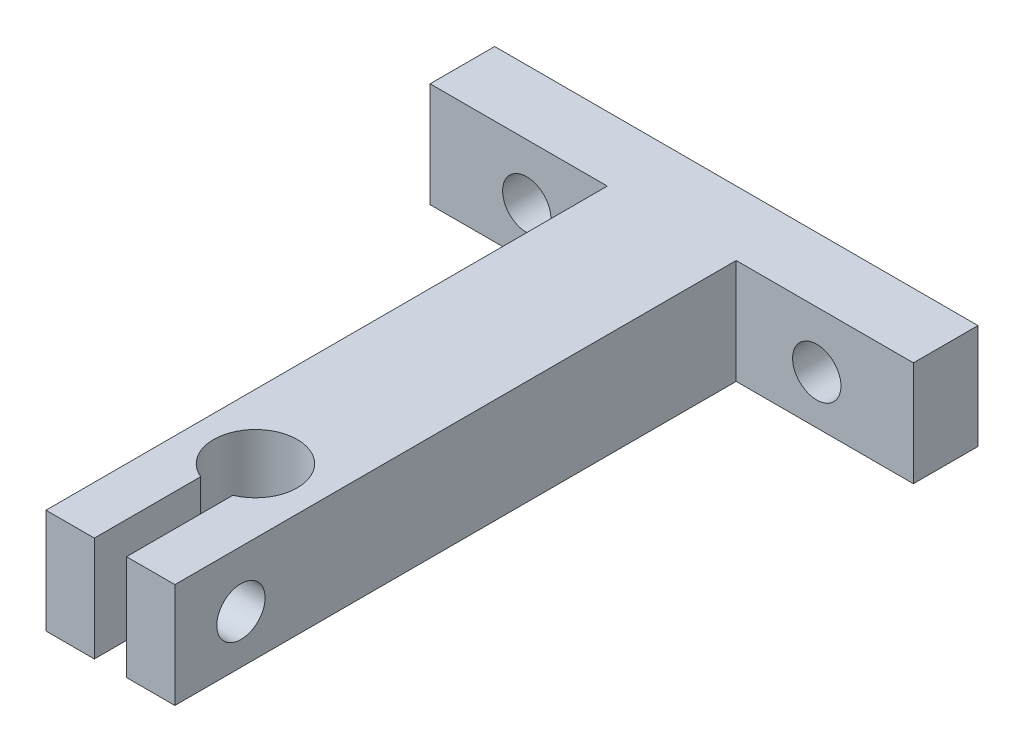
from build123d import *

# Parameters (mm, degrees)
SKETCH1_W              = 30
SKETCH1_H              = 4.008403362
BOSS_EXTRUDE1_DEPTH    = 7
SKETCH2_R              = 1.5
CUT_EXTRUDE1_DEPTH     = 20
SKETCH3_R              = 1.5
CUT_EXTRUDE2_DEPTH     = 5
CHAMFER1_SIZE          = 0.5
CHAMFER1_SIZE2         = 0.595876796
CHAMFER1_PART_2_SIZE   = 0.5
CHAMFER1_PART_2_SIZE2  = 0.595876796
CHAMFER1_PART_3_SIZE   = 0.5
CHAMFER1_PART_3_SIZE2  = 0.595876796
CHAMFER1_PART_4_SIZE   = 0.5
CHAMFER1_PART_4_SIZE2  = 0.595876796
CHAMFER1_PART_5_SIZE   = 0.5
CHAMFER1_PART_5_SIZE2  = 0.595876796
CHAMFER1_PART_6_SIZE   = 0.5
CHAMFER1_PART_6_SIZE2  = 0.595876796
CHAMFER1_PART_7_SIZE   = 0.5
CHAMFER1_PART_7_SIZE2  = 0.595876796
CHAMFER1_PART_8_SIZE   = 0.5
CHAMFER1_PART_8_SIZE2  = 0.595876796
CHAMFER1_PART_9_SIZE   = 0.5
CHAMFER1_PART_9_SIZE2  = 0.595876796
CHAMFER1_PART_10_SIZE  = 0.5
CHAMFER1_PART_10_SIZE2 = 0.595876796
CHAMFER1_PART_11_SIZE  = 0.5
CHAMFER1_PART_11_SIZE2 = 0.595876796
CHAMFER1_PART_12_SIZE  = 0.5
CHAMFER1_PART_12_SIZE2 = 0.595876796


with BuildPart() as part:
    # Sketch1 → Boss-Extrude1 (new body)
    with BuildSketch(Plane(origin=(0, 0, 0), x_dir=(1, 0, 0), z_dir=(0, 1, 0))):
        with BuildLine():
            Line((4, -2.004201681), (-4, -2.004201681))
            Line((-4, -2.004201681), (-4, -36.845798319))
            Line((-4, -36.845798319), (-1, -36.845798319))
            Line((-1, -36.845798319), (-1, -30.245798319))
            ThreePointArc((-1, -30.245798319), (-1.44222051, -25.682467554), (2.6, -27.845798319))
            ThreePointArc((2.6, -27.845798319), (2.163330765, -29.28801883), (1, -30.245798319))
            Line((1, -30.245798319), (1, -36.845798319))
            Line((1, -36.845798319), (4, -36.845798319))
            Line((4, -36.845798319), (4, -2.004201681))
        make_face()
        Rectangle(SKETCH1_W, SKETCH1_H)
    extrude(amount=BOSS_EXTRUDE1_DEPTH)

    # Sketch2 → Cut-Extrude1 (cut, through all)
    with BuildSketch(Plane(origin=(4, 0, 0), x_dir=(0, 0, -1), z_dir=(1, 0, 0))):
        with Locations((-32.745798319, 3.5)):
            Circle(SKETCH2_R)
    extrude(amount=-CUT_EXTRUDE1_DEPTH, mode=Mode.SUBTRACT)

    # Sketch3 → Cut-Extrude2 (cut)
    with BuildSketch(Plane.XY.offset(2.004201681)):
        with Locations((9, 3.5)):
            Circle(SKETCH3_R)
        with Locations((-9, 3.5)):
            Circle(SKETCH3_R)
    extrude(amount=-CUT_EXTRUDE2_DEPTH, mode=Mode.SUBTRACT)

    # Chamfer1
    chamfer1_edges = [part.edges().sort_by_distance(p)[0] for p in [
        (-1, 0, 33.545798319),
    ]]
    chamfer1_side = [part.faces().sort_by_distance(p)[0] for p in [
        (-1, 3.5, 36.749590212),
    ]]
    chamfer(chamfer1_edges, length=CHAMFER1_SIZE, length2=CHAMFER1_SIZE2, reference=chamfer1_side[0])

    # Chamfer1 part 2
    chamfer1_part_2_edges = [part.edges().sort_by_distance(p)[0] for p in [
        (-2.5, 0, 36.845798319),
    ]]
    chamfer1_part_2_side = [part.faces().sort_by_distance(p)[0] for p in [
        (-2.5, 3.5, 36.845798319),
    ]]
    chamfer(chamfer1_part_2_edges, length=CHAMFER1_PART_2_SIZE, length2=CHAMFER1_PART_2_SIZE2, reference=chamfer1_part_2_side[0])

    # Chamfer1 part 3
    chamfer1_part_3_edges = [part.edges().sort_by_distance(p)[0] for p in [
        (-4, 0, 19.425),
    ]]
    chamfer1_part_3_side = [part.faces().sort_by_distance(p)[0] for p in [
        (-4, 3.5, 19.027406284),
    ]]
    chamfer(chamfer1_part_3_edges, length=CHAMFER1_PART_3_SIZE, length2=CHAMFER1_PART_3_SIZE2, reference=chamfer1_part_3_side[0])

    # Chamfer1 part 4
    chamfer1_part_4_edges = [part.edges().sort_by_distance(p)[0] for p in [
        (-9.5, 0, 2.004201681),
    ]]
    chamfer1_part_4_side = [part.faces().sort_by_distance(p)[0] for p in [
        (-9.5, 0.130384048, 2.004201681),
    ]]
    chamfer(chamfer1_part_4_edges, length=CHAMFER1_PART_4_SIZE, length2=CHAMFER1_PART_4_SIZE2, reference=chamfer1_part_4_side[0])

    # Chamfer1 part 5
    chamfer1_part_5_edges = [part.edges().sort_by_distance(p)[0] for p in [
        (-15, 0, 0),
    ]]
    chamfer1_part_5_side = [part.faces().sort_by_distance(p)[0] for p in [
        (-15, 3.5, 0),
    ]]
    chamfer(chamfer1_part_5_edges, length=CHAMFER1_PART_5_SIZE, length2=CHAMFER1_PART_5_SIZE2, reference=chamfer1_part_5_side[0])

    # Chamfer1 part 6
    chamfer1_part_6_edges = [part.edges().sort_by_distance(p)[0] for p in [
        (0, 0, -2.004201681),
    ]]
    chamfer1_part_6_side = [part.faces().sort_by_distance(p)[0] for p in [
        (0, 3.5, -2.004201681),
    ]]
    chamfer(chamfer1_part_6_edges, length=CHAMFER1_PART_6_SIZE, length2=CHAMFER1_PART_6_SIZE2, reference=chamfer1_part_6_side[0])

    # Chamfer1 part 7
    chamfer1_part_7_edges = [part.edges().sort_by_distance(p)[0] for p in [
        (15, 0, 0),
    ]]
    chamfer1_part_7_side = [part.faces().sort_by_distance(p)[0] for p in [
        (15, 3.5, 0),
    ]]
    chamfer(chamfer1_part_7_edges, length=CHAMFER1_PART_7_SIZE, length2=CHAMFER1_PART_7_SIZE2, reference=chamfer1_part_7_side[0])

    # Chamfer1 part 8
    chamfer1_part_8_edges = [part.edges().sort_by_distance(p)[0] for p in [
        (9.5, 0, 2.004201681),
    ]]
    chamfer1_part_8_side = [part.faces().sort_by_distance(p)[0] for p in [
        (9.5, 0.130384048, 2.004201681),
    ]]
    chamfer(chamfer1_part_8_edges, length=CHAMFER1_PART_8_SIZE, length2=CHAMFER1_PART_8_SIZE2, reference=chamfer1_part_8_side[0])

    # Chamfer1 part 9
    chamfer1_part_9_edges = [part.edges().sort_by_distance(p)[0] for p in [
        (4, 0, 19.425),
    ]]
    chamfer1_part_9_side = [part.faces().sort_by_distance(p)[0] for p in [
        (4, 3.5, 19.027406284),
    ]]
    chamfer(chamfer1_part_9_edges, length=CHAMFER1_PART_9_SIZE, length2=CHAMFER1_PART_9_SIZE2, reference=chamfer1_part_9_side[0])

    # Chamfer1 part 10
    chamfer1_part_10_edges = [part.edges().sort_by_distance(p)[0] for p in [
        (2.5, 0, 36.845798319),
    ]]
    chamfer1_part_10_side = [part.faces().sort_by_distance(p)[0] for p in [
        (2.5, 3.5, 36.845798319),
    ]]
    chamfer(chamfer1_part_10_edges, length=CHAMFER1_PART_10_SIZE, length2=CHAMFER1_PART_10_SIZE2, reference=chamfer1_part_10_side[0])

    # Chamfer1 part 11
    chamfer1_part_11_edges = [part.edges().sort_by_distance(p)[0] for p in [
        (1, 0, 33.545798319),
    ]]
    chamfer1_part_11_side = [part.faces().sort_by_distance(p)[0] for p in [
        (1, 3.5, 30.342006427),
    ]]
    chamfer(chamfer1_part_11_edges, length=CHAMFER1_PART_11_SIZE, length2=CHAMFER1_PART_11_SIZE2, reference=chamfer1_part_11_side[0])

    # Chamfer1 part 12
    chamfer1_part_12_edges = [part.edges().sort_by_distance(p)[0] for p in [
        (-1.44222051, 0, 25.682467554),
    ]]
    chamfer1_part_12_side = [part.faces().sort_by_distance(p)[0] for p in [
        (-1.44222051, 3.5, 25.682467554),
    ]]
    chamfer(chamfer1_part_12_edges, length=CHAMFER1_PART_12_SIZE, length2=CHAMFER1_PART_12_SIZE2, reference=chamfer1_part_12_side[0])


solid = part.part
